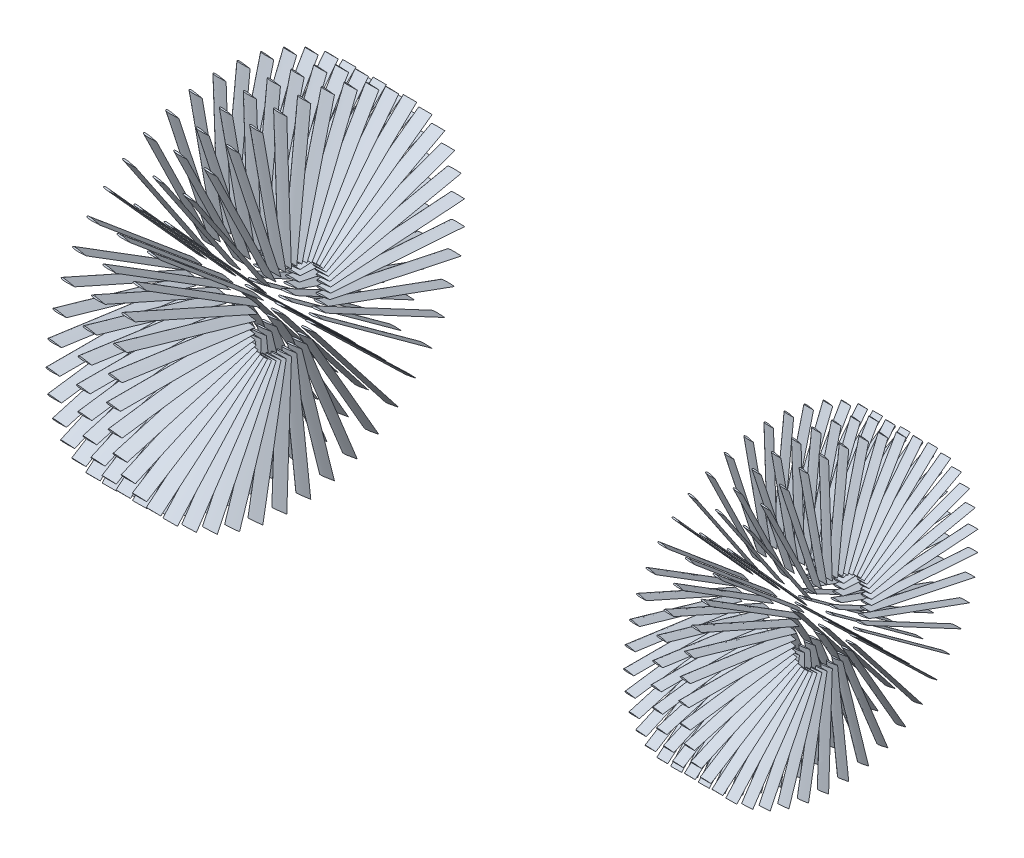
from build123d import *

# Parameters (mm, degrees)
BOSS_EXTRUDE3_DEPTH   = 97.5
BOSS_EXTRUDE3_2_DEPTH = 97.5
SKETCH6_R             = 7.868048589
CUT_EXTRUDE1_DEPTH    = 20
CIRPATTERN4_COUNT     = 45
CIRPATTERN4_2_COUNT   = 45
LPATTERN1_COUNT       = 3
LPATTERN1_PITCH       = 22
LPATTERN2_COUNT       = 3
LPATTERN2_PITCH       = 20


with BuildPart() as part:
    # Sketch1 → Boss-Extrude3 (new body)
    with BuildSketch(Plane.XY):
        with BuildLine():
            add(Edge.make_bspline(
                [(0.036378043, 0.852190878), (0.706817283, 1.611585522), (10.000000412, 0)],
                knots=[0, 0, 0, 1, 1, 1], degree=2))
            add(Edge.make_bspline(
                [(0.036378043, 0.852190878), (-1.003824845, -0.622937235), (10.000000412, 0)],
                knots=[0, 0, 0, 1, 1, 1], degree=2))
        make_face()
    extrude(amount=BOSS_EXTRUDE3_DEPTH)

    # CirPattern4 2: part ×45 about axis
    cirpattern4_2_axis = Axis((-186.352236215, 0, -27.5), (1, 0, 0))


with BuildPart() as body_2:
    # Sketch1 → Boss-Extrude3 2 (new body)
    with BuildSketch(Plane.XY):
        with BuildLine():
            add(Edge.make_bspline(
                [(354.999381662, 0.653404154), (355.325170057, 1.762084489), (362.471085976, 0.002531939)],
                knots=[0, 0, 0, 1, 1, 1], degree=2))
            add(Edge.make_bspline(
                [(354.999381662, 0.653404154), (354.820263876, -0.223302151), (362.471085976, 0.002531939)],
                knots=[0, 0, 0, 1, 1, 1], degree=2))
        make_face()
    extrude(amount=BOSS_EXTRUDE3_2_DEPTH)

    # Sketch6 → Cut-Extrude1 (cut)
    with BuildSketch(Plane.XY.offset(97.5)):
        with Locations((362.471085976, 0.002531939)):
            Circle(SKETCH6_R)
    extrude(amount=-CUT_EXTRUDE1_DEPTH, mode=Mode.SUBTRACT)

    # CirPattern4: body 2 ×45 about axis
    cirpattern4_axis = Axis((-186.352236215, 0, -27.5), (1, 0, 0))


with BuildPart() as body_2_1:
    add(body_2.part)
    for i in range(1, CIRPATTERN4_COUNT):
        add(body_2.part.rotate(cirpattern4_axis, i * 360 / CIRPATTERN4_COUNT))


with BuildPart() as part_1:
    add(part.part)
    for i in range(1, CIRPATTERN4_2_COUNT):
        add(part.part.rotate(cirpattern4_2_axis, i * 360 / CIRPATTERN4_2_COUNT))


with BuildPart() as lpattern1_1:
    # LPattern1: pattern copy
    add(part_1.part.moved(Location(Vector(-1, 0, 0) * (1 * LPATTERN1_PITCH))))


with BuildPart() as lpattern1_2:
    # LPattern1: pattern copy
    add(part_1.part.moved(Location(Vector(-1, 0, 0) * (2 * LPATTERN1_PITCH))))


with BuildPart() as lpattern2_1:
    # LPattern2: pattern copy
    add(body_2_1.part.moved(Location(Vector(1, 0, 0) * (1 * LPATTERN2_PITCH))))


with BuildPart() as lpattern2_2:
    # LPattern2: pattern copy
    add(body_2_1.part.moved(Location(Vector(1, 0, 0) * (2 * LPATTERN2_PITCH))))


solid = Compound([body_2_1.part, part_1.part, lpattern1_1.part, lpattern1_2.part, lpattern2_1.part, lpattern2_2.part])
